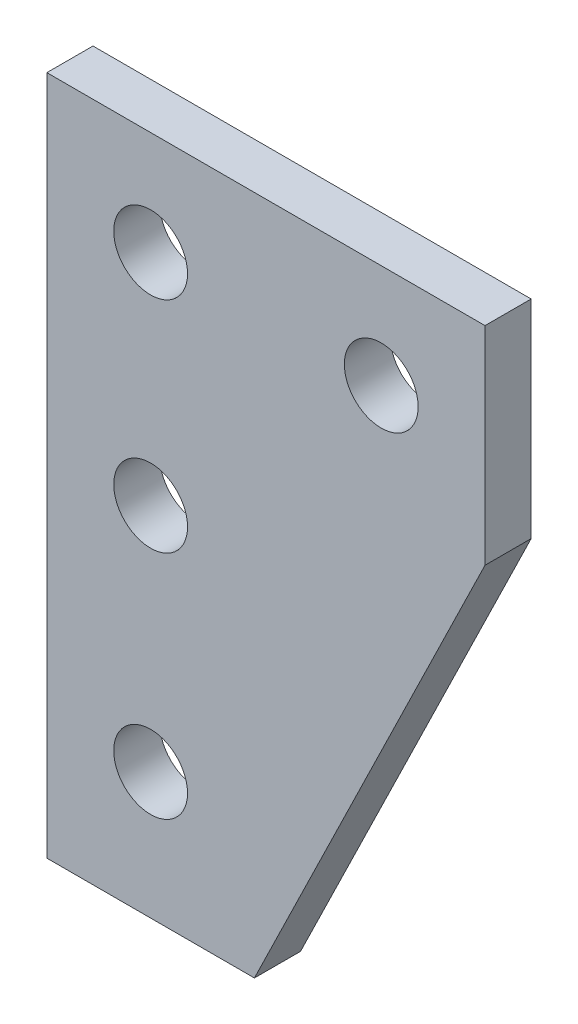
from build123d import *

# Parameters (mm, degrees)
SKETCH_1_W          = 50
SKETCH_1_H          = 50
EXTRUDE_1_DEPTH     = 2
SKETCH_2_R          = 1.6
CUT_EXTRUDE_1_DEPTH = 10
SKETCH_3_W          = 76.549088161
SKETCH_3_H          = 63.496312915
CUT_EXTRUDE_3_DEPTH = 10


with BuildPart() as part:
    # ｽｹｯﾁ1 → ﾎﾞｽ - 押し出し1 (new body)
    with BuildSketch(Plane.XY):
        Rectangle(SKETCH_1_W, SKETCH_1_H)
    extrude(amount=EXTRUDE_1_DEPTH)

    # ｽｹｯﾁ2 → ｶｯﾄ - 押し出し1 (cut)
    with BuildSketch(Plane.XY.offset(2)):
        Circle(SKETCH_2_R)
        with Locations((0, -9.51)):
            Circle(SKETCH_2_R)
        with Locations((0, -19.51)):
            Circle(SKETCH_2_R)
        with Locations((10, 0)):
            Circle(SKETCH_2_R)
    extrude(amount=-CUT_EXTRUDE_1_DEPTH, mode=Mode.SUBTRACT)

    # ｽｹｯﾁ3 → ｶｯﾄ - 押し出し3 (cut)
    with BuildSketch(Plane.XY.offset(2)):
        with Locations((-0.951764861, 3.501134841)):
            Rectangle(SKETCH_3_W, SKETCH_3_H)
        Polygon((14.5, -4.5), (4.5, -25), (-4.5, -25), (-4.5, 4.5), (14.5, 4.5), align=None, mode=Mode.SUBTRACT)
    extrude(amount=-CUT_EXTRUDE_3_DEPTH, mode=Mode.SUBTRACT)


solid = part.part
